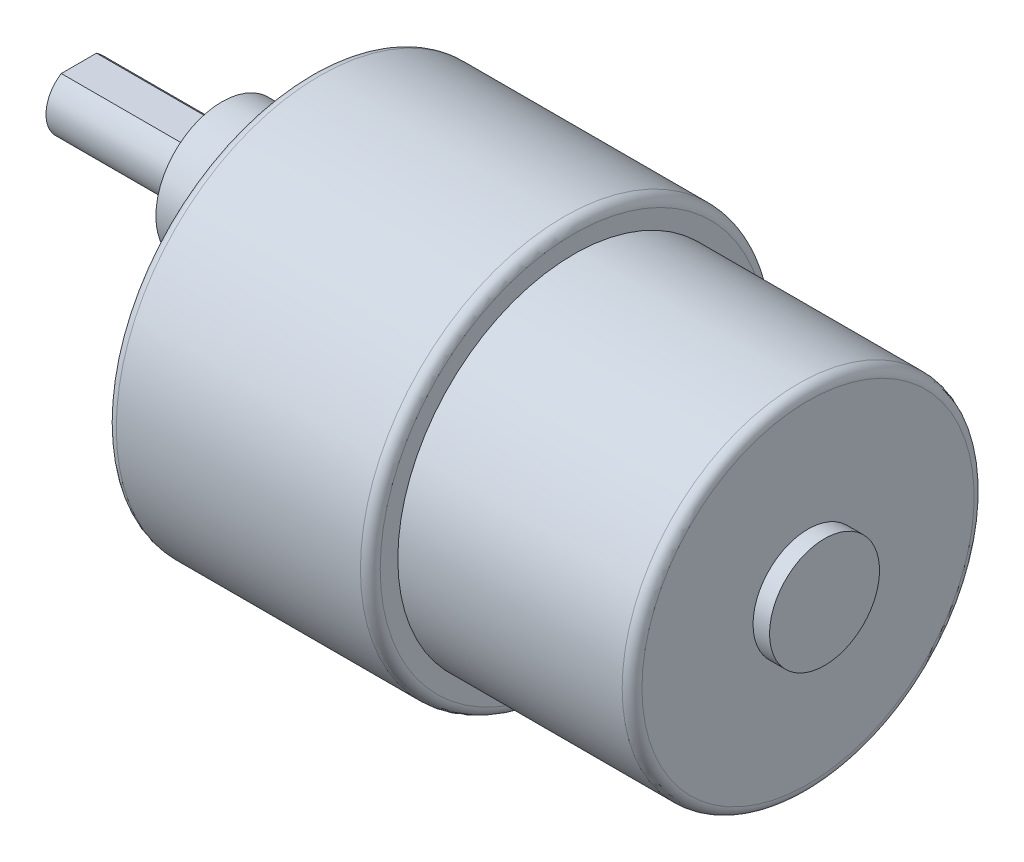
from build123d import *

# Parameters (mm, degrees)
SKETCH2_R           = 6
BOSS_EXTRUDE1_DEPTH = 8
SKETCH3_R           = 2.990422361
BOSS_EXTRUDE2_DEPTH = 13
CUT_EXTRUDE1_DEPTH  = 11
CUT_EXTRUDE2_DEPTH  = 1
SKETCH7_R           = 0.75
CUT_EXTRUDE4_DEPTH  = 2
CIRPATTERN1_COUNT   = 6


with BuildPart() as part:
    # Sketch1 → Revolve2 (revolve)
    with BuildSketch(Plane(origin=(0, 0, 0), x_dir=(1, 0, 0), z_dir=(0, 1, 0))):
        with BuildLine():
            Line((-23.3, 0), (23.5, 0))
            Line((23.5, 0), (23.5, 5))
            Line((23.5, 5), (22, 5))
            Line((22, 5), (22, 15.1))
            ThreePointArc((22, 15.1), (21.736396103, 15.736396103), (21.1, 16))
            Line((21.1, 16), (0.7, 16))
            Line((0.7, 16), (0.7, 17.6))
            ThreePointArc((0.7, 17.6), (0.436396103, 18.236396103), (-0.2, 18.5))
            Line((-0.2, 18.5), (-22.4, 18.5))
            ThreePointArc((-22.4, 18.5), (-23.036396103, 18.236396103), (-23.3, 17.6))
            Line((-23.3, 17.6), (-23.3, 0))
        make_face()
    revolve(axis=Axis((-35.546651827, 0, 0), (1, 0, 0)))

    # Sketch2 → Boss-Extrude1 (add)
    with BuildSketch(Plane.ZY.offset(23.3)):
        with Locations((0, 6)):
            Circle(SKETCH2_R)
    extrude(amount=BOSS_EXTRUDE1_DEPTH)

    # Sketch3 → Boss-Extrude2 (add)
    with BuildSketch(Plane.ZY.offset(31.3)):
        with Locations((0, 6)):
            Circle(SKETCH3_R)
    extrude(amount=BOSS_EXTRUDE2_DEPTH)

    # Sketch5 → Cut-Extrude1 (cut)
    with BuildSketch(Plane.ZY.offset(44.3)):
        with BuildLine():
            Line((-1.6, 8.526385936), (1.6, 8.526385936))
            ThreePointArc((1.6, 8.526385936), (0, 8.990422361), (-1.6, 8.526385936))
        make_face()
    extrude(amount=-CUT_EXTRUDE1_DEPTH, mode=Mode.SUBTRACT)

    # Sketch6 → Cut-Extrude2 (cut)
    with BuildSketch(Plane.ZY.offset(23.3)):
        with BuildLine():
            ThreePointArc((-7.110243003, 9.666666667), (0, -2), (7.110243003, 9.666666667))
            ThreePointArc((7.110243003, 9.666666667), (0, -12), (-7.110243003, 9.666666667))
        make_face()
    extrude(amount=-CUT_EXTRUDE2_DEPTH, mode=Mode.SUBTRACT)

    # Sketch7 → Cut-Extrude4 (cut)
    with BuildSketch(Plane.ZY.offset(23.3)):
        with Locations((15.5, 0)):
            Circle(SKETCH7_R)
    cut_extrude4 = extrude(amount=-CUT_EXTRUDE4_DEPTH, mode=Mode.SUBTRACT)

    # CirPattern1: Cut-Extrude4 ×6 about axis
    cirpattern1_axis = Axis((0, 0, 0), (1, 0, 0))
    for i in range(1, CIRPATTERN1_COUNT):
        add(cut_extrude4.rotate(cirpattern1_axis, i * 360 / CIRPATTERN1_COUNT), mode=Mode.SUBTRACT)


solid = part.part
